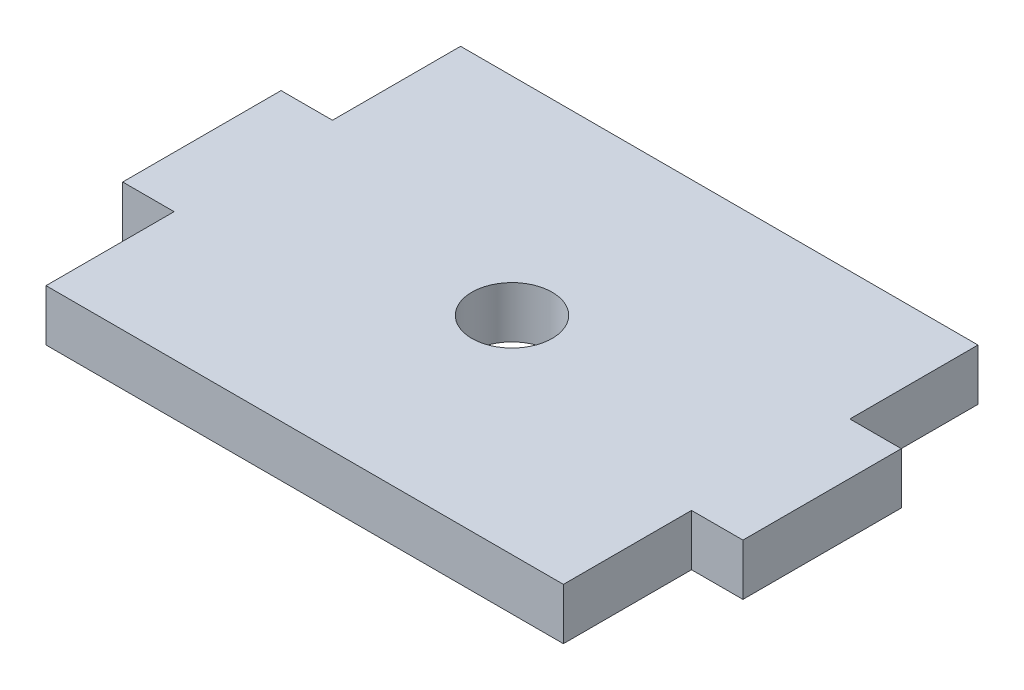
from build123d import *

# Parameters (mm, degrees)
SKETCH1_R           = 2.4780875
BOSS_EXTRUDE1_DEPTH = 1.5875


with BuildPart() as part:
    # Sketch1 → Boss-Extrude1 (new body, symmetric)
    with BuildSketch(Plane(origin=(0, 0, 0), x_dir=(1, 0, 0), z_dir=(0, 1, 0))):
        Polygon((-15.9766, 12.8016), (15.9766, 12.8016), (15.9766, 4.8895), (19.1516, 4.8895), (19.1516, -4.8895), (15.9766, -4.8895), (15.9766, -12.8016), (-15.9766, -12.8016), (-15.9766, -4.8895), (-19.1516, -4.8895), (-19.1516, 4.8895), (-15.9766, 4.8895), align=None)
        Circle(SKETCH1_R, mode=Mode.SUBTRACT)
    extrude(amount=BOSS_EXTRUDE1_DEPTH, both=True)


solid = part.part
